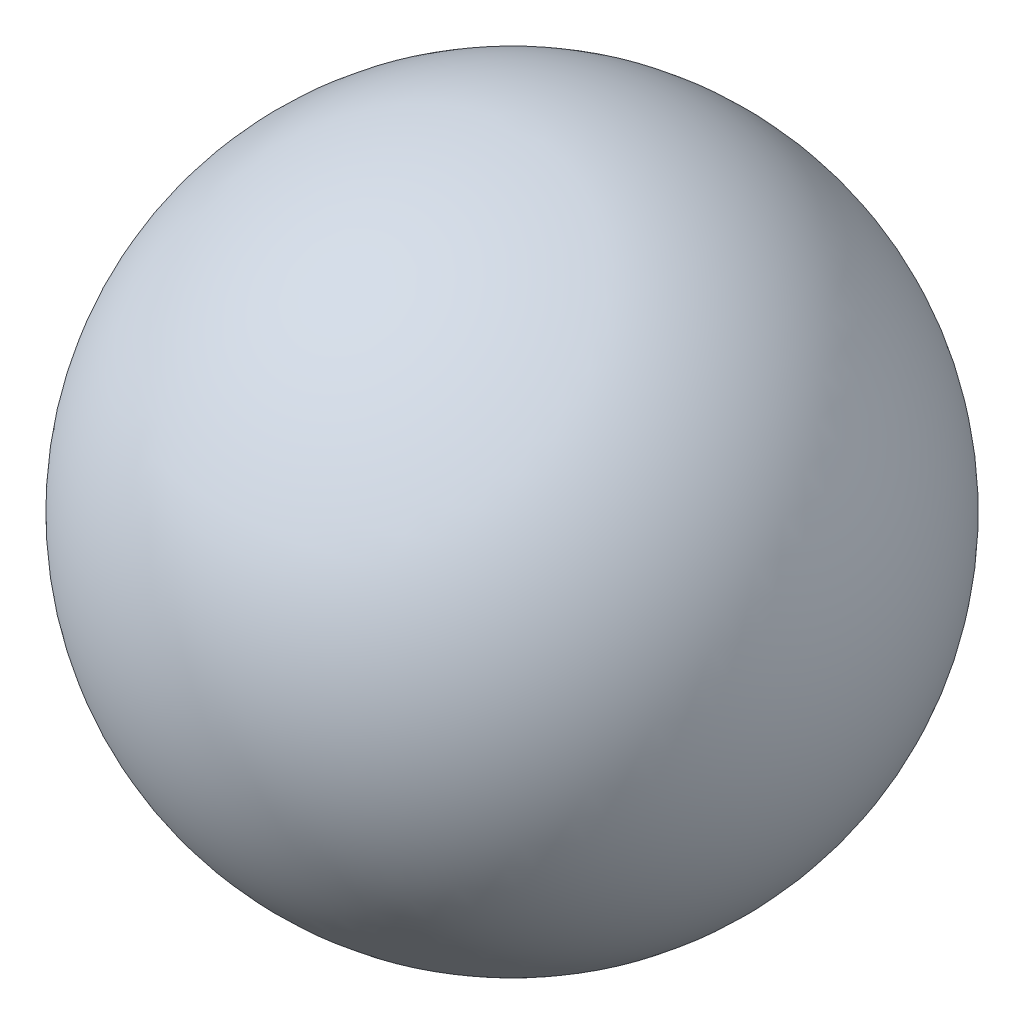
from build123d import *


with BuildPart() as part:
    # Sketch1 → Revolve1 (revolve)
    with BuildSketch(Plane.XY):
        with BuildLine():
            Line((0, -2.261977216), (0, -9.261977216))
            ThreePointArc((0, -9.261977216), (3.5, -5.761977216), (0, -2.261977216))
        make_face()
    revolve(axis=Axis((0, 0, 0), (0, -1, 0)))


solid = part.part
